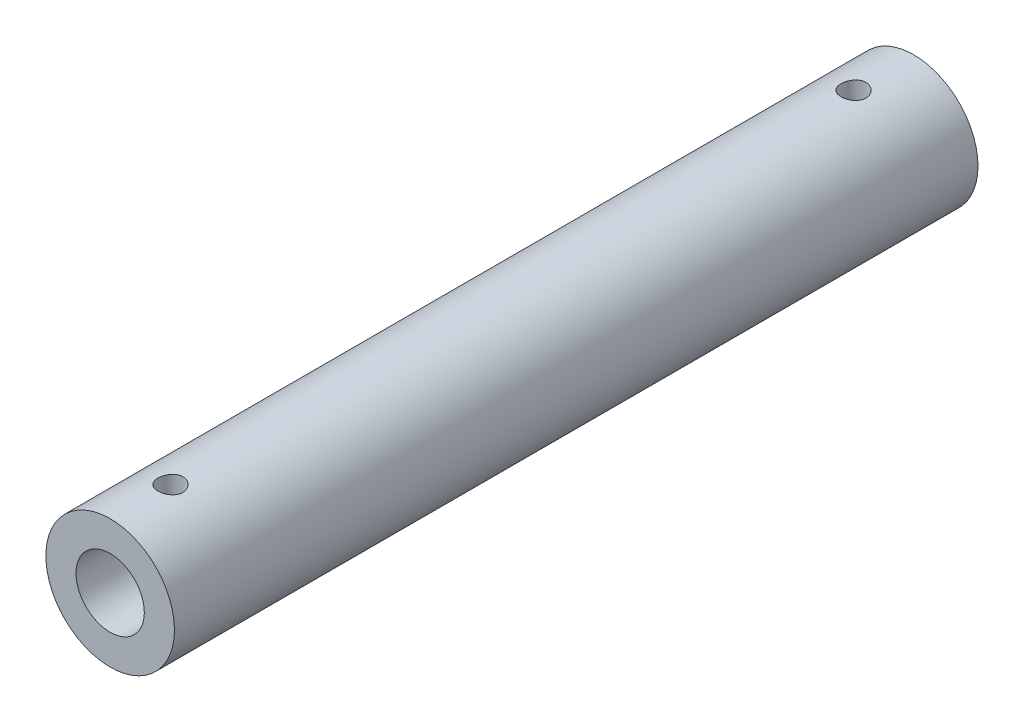
from build123d import *

# Parameters (mm, degrees)
BOSS_EXTRUDE1_DEPTH      = 100
BOSS_EXTRUDE1_DEPTH_BACK = 100
SKETCH2_R                = 16
SKETCH2_R_2              = 8.5
SKETCH4_R                = 3.1
CUT_EXTRUDE1_DEPTH       = 103.528044944


with BuildPart() as part:
    # Sketch2 → Boss-Extrude1 (new, two sides: drawn at the far end of the back side and taken through both)
    with BuildSketch(Plane.XY.offset(-BOSS_EXTRUDE1_DEPTH_BACK)):
        Circle(SKETCH2_R)
        Circle(SKETCH2_R_2, mode=Mode.SUBTRACT)
    extrude(amount=BOSS_EXTRUDE1_DEPTH + BOSS_EXTRUDE1_DEPTH_BACK)

    # Sketch4 → Cut-Extrude1 (cut, through all)
    with BuildSketch(Plane(origin=(0, 0, 0), x_dir=(1, 0, 0), z_dir=(0, 1, 0))):
        with Locations((0, -85)):
            Circle(SKETCH4_R)
    cut_extrude1 = extrude(amount=CUT_EXTRUDE1_DEPTH, mode=Mode.SUBTRACT)

    # Mirror1: Cut-Extrude1 across plane
    add(cut_extrude1.mirror(Plane.XY), mode=Mode.SUBTRACT)


solid = part.part
